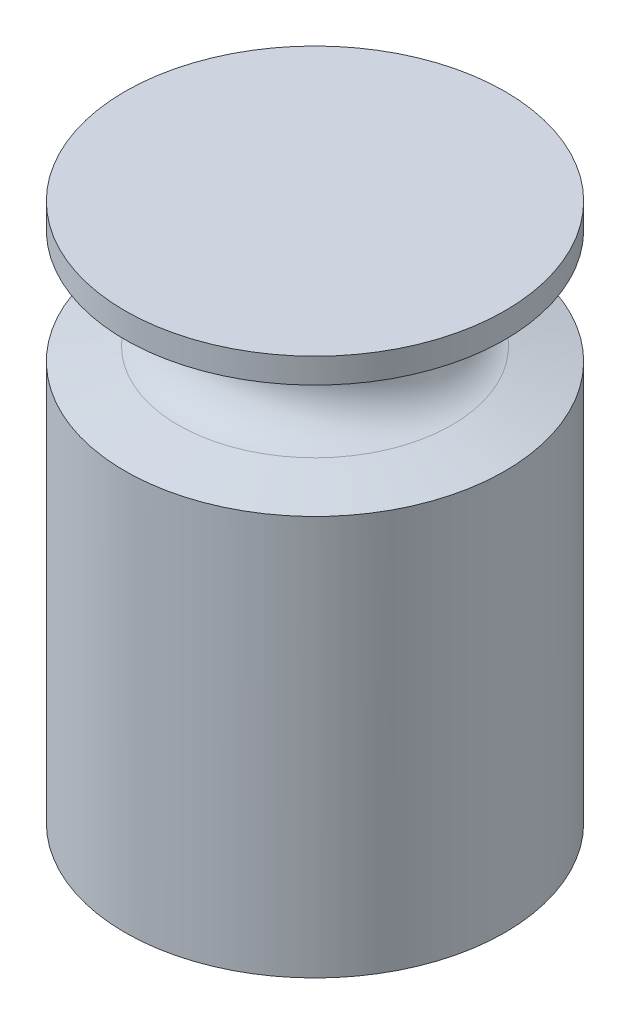
from build123d import *

# Parameters (mm, degrees)
SKETCH1_R           = 25.05
BOSS_EXTRUDE1_DEPTH = 71


with BuildPart() as part:
    # Sketch1 → Boss-Extrude1 (new body)
    with BuildSketch(Plane(origin=(0, 0, 0), x_dir=(1, 0, 0), z_dir=(0, 1, 0))):
        Circle(SKETCH1_R)
    extrude(amount=BOSS_EXTRUDE1_DEPTH)

    # Sketch2 → Cut-Revolve1 (revolve, cut)
    with BuildSketch(Plane.XY):
        with BuildLine():
            Line((-25.05, 67.7), (-18.045116148, 65.953486299))
            ThreePointArc((-18.045116148, 65.953486299), (-13.55, 60.2), (-18.045116148, 54.446513701))
            Line((-18.045116148, 54.446513701), (-25.05, 52.7))
            Line((-25.05, 52.7), (-25.05, 67.7))
        make_face()
    revolve(axis=Axis((0, -3.55, 0), (0, 1, 0)), mode=Mode.SUBTRACT)


solid = part.part
